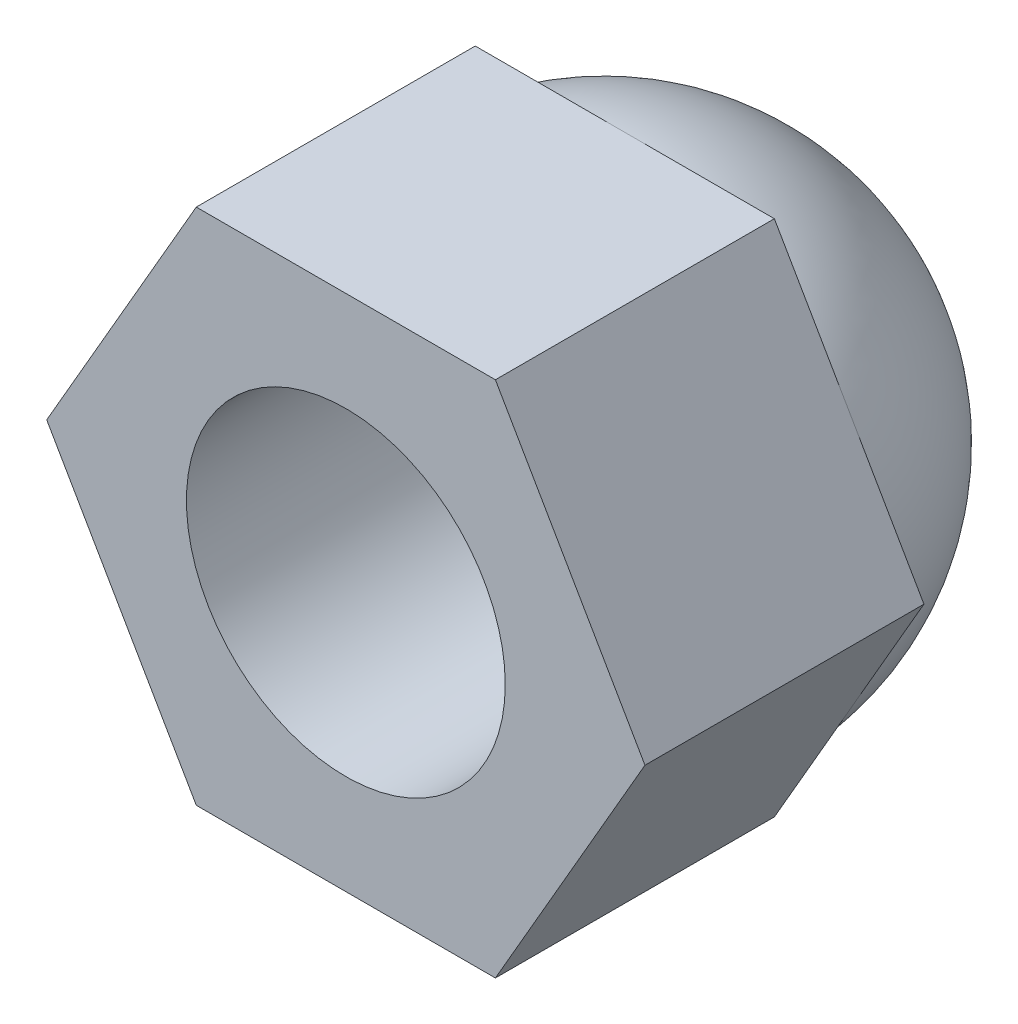
from build123d import *

# Parameters (mm, degrees)
SALIENTE_EXTRUIR1_DEPTH = 7
CROQUIS3_R              = 4
CORTAR_EXTRUIR1_DEPTH   = 7


with BuildPart() as part:
    # Croquis1 → Saliente-Extruir1 (new body)
    with BuildSketch(Plane.XY):
        Polygon((7.505553499, 0), (3.75277675, 6.5), (-3.75277675, 6.5), (-7.505553499, 0), (-3.75277675, -6.5), (3.75277675, -6.5), align=None)
    extrude(amount=SALIENTE_EXTRUIR1_DEPTH)

    # Croquis2 → Revolución1 (revolve)
    with BuildSketch(Plane(origin=(0, 0, 0), x_dir=(0, 0, -1), z_dir=(1, 0, 0))):
        with BuildLine():
            Line((0, 0), (6, 0))
            ThreePointArc((6, 0), (4.270697462, -4.422951503), (0, -6.5))
            Line((0, -6.5), (0, 0))
        make_face()
    revolve(axis=Axis((0, 0, 0), (0, 0, -1)))

    # Croquis3 → Cortar-Extruir1 (cut)
    with BuildSketch(Plane.XY.offset(7)):
        Circle(CROQUIS3_R)
    extrude(amount=-CORTAR_EXTRUIR1_DEPTH, mode=Mode.SUBTRACT)


solid = part.part
